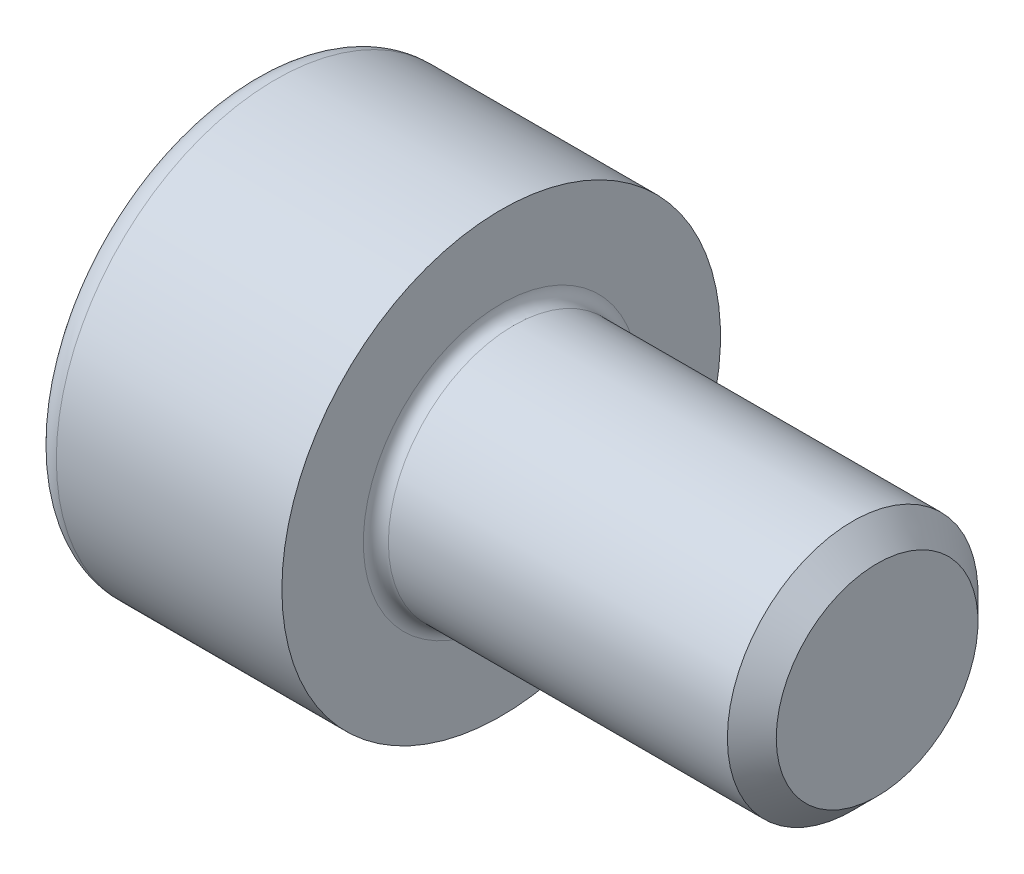
from build123d import *

# Parameters (mm, degrees)
FILLET1_R   = 0.2
FILLET2_R   = 0.4
HEX_2_DEPTH = 2


with BuildPart() as part:
    # BodySke → Base-Revolve (revolve)
    with BuildSketch(Plane.XY):
        Polygon((0, 0), (0, 3.5), (4, 3.5), (4, 2), (9.61, 2), (10, 1.61), (10, 0), align=None)
    revolve(axis=Axis((-31.75, 0, 0), (1, 0, 0)))

    # Fillet1
    fillet1_edges = [part.edges().sort_by_distance(p)[0] for p in [
        (4, -2, 0),
    ]]
    fillet(fillet1_edges, radius=FILLET1_R)

    # Fillet2
    fillet2_edges = [part.edges().sort_by_distance(p)[0] for p in [
        (0, -3.5, 0),
    ]]
    fillet(fillet2_edges, radius=FILLET2_R)

    # Sketch2 → Hex-PreBroach (revolve, cut)
    with BuildSketch(Plane.XY):
        Polygon((0, 1.51), (2, 1.51), (2.871798906, 0), (0, 0), align=None)
    revolve(axis=Axis((0, 0, 0), (1, 0, 0)), mode=Mode.SUBTRACT)

    # Sketch3 → Hex 2 (cut)
    with BuildSketch(Plane(origin=(0, 0, 0), x_dir=(0, 0.5, 0.866025404), z_dir=(-1, 0, 0))):
        Polygon((0.871798906, 1.51), (-0.871798906, 1.51), (-1.743597813, 0), (-0.871798906, -1.51), (0.871798906, -1.51), (1.743597813, 0), align=None)
    extrude(amount=-HEX_2_DEPTH, mode=Mode.SUBTRACT)


solid = part.part
